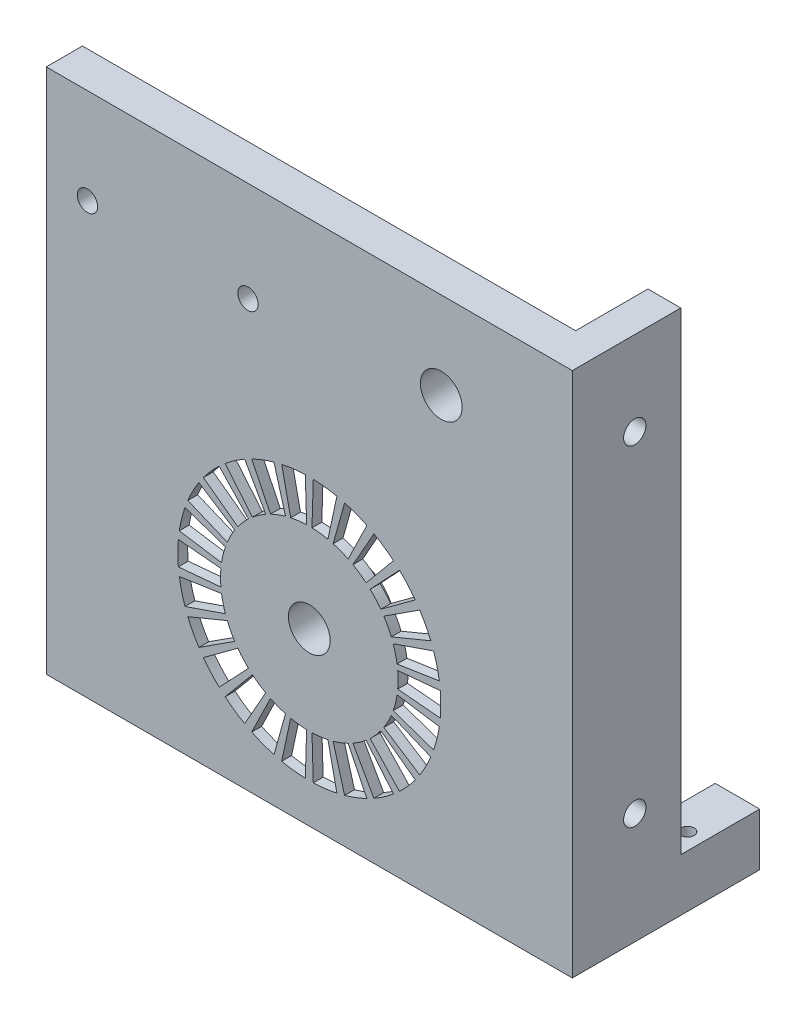
from build123d import *

# Parameters (mm, degrees)
LED_PANEL_W                                     = 80
LED_PANEL_H                                     = 80
EXTRUDE_LED_PANEL_DEPTH                         = 2.5
SKETCH3_R                                       = 5.998748594
SKETCH3_R_2                                     = 6.002880514
BOSS_EXTRUDE2_DEPTH                             = 7
SKETCH1_R                                       = 3.175
CUT_ARROW_INDICATION_HOLES_DEPTH                = 8
SKETCH4_R                                       = 3.175
CUT_HOLE_FOR_SECONDARY_ROD_DEPTH                = 3.5
CUT_HOLE_FOR_SECONDARY_ROD_DEPTH_BACK           = 7
SKETCH2_R                                       = 5.998748594
CUT_SLOT_FOR_PCB_DEPTH                          = 1
BOSS_EXTRUDE3_DEPTH                             = 3
SKETCH9_W                                       = 16.5
SKETCH9_H                                       = 80
BOSS_EXTRUDE4_DEPTH                             = 5
BOSS_EXTRUDE5_DEPTH                             = 12
BOSS_EXTRUDE5_DEPTH_BACK                        = 16.5
SKETCH12_R                                      = 1
CUT_EXTRUDE1_DEPTH                              = 9
SKETCH13_R                                      = 3
BOSS_EXTRUDE6_DEPTH                             = 3
SKETCH14_R                                      = 1.55
CUT_EXTRUDE2_DEPTH                              = 6.5
CSK_FOR_M3_FLAT_HEAD_MACHINE_SCREW1_D           = 3.4
CSK_FOR_M3_FLAT_HEAD_MACHINE_SCREW1_DEPTH       = 5
CSK_FOR_M3_FLAT_HEAD_MACHINE_SCREW1_CSINK_D     = 6.3
CSK_FOR_M3_FLAT_HEAD_MACHINE_SCREW1_CSINK_ANGLE = 90


with BuildPart() as part:
    # LED panel → Extrude LED panel (new body)
    with BuildSketch(Plane.XY):
        Rectangle(LED_PANEL_W, LED_PANEL_H)
    extrude(amount=EXTRUDE_LED_PANEL_DEPTH)

    # Sketch3 → Boss-Extrude2 (add)
    with BuildSketch(Plane.XY.offset(2.5)):
        with Locations((0, -14)):
            Circle(SKETCH3_R)
        with Locations((20.072118416, 26.780555807)):
            Circle(SKETCH3_R_2)
    extrude(amount=-BOSS_EXTRUDE2_DEPTH)

    # Sketch1 → Cut arrow indication holes (cut, through all)
    with BuildSketch(Plane.XY.offset(2.5)):
        with Locations((0, -14)):
            Circle(SKETCH1_R)
        with BuildLine():
            Line((13.444603528, -12.778265176), (19.917931152, -12.190022483))
            ThreePointArc((19.917931152, -12.190022483), (20, -14), (19.917931152, -15.809977517))
            Line((19.917931152, -15.809977517), (13.444603528, -15.221734824))
            ThreePointArc((13.444603528, -15.221734824), (13.5, -14), (13.444603528, -12.778265176))
        make_face()
        with BuildLine():
            Line((13.346308065, -16.031270794), (19.772308244, -17.009290065))
            ThreePointArc((19.772308244, -17.009290065), (19.418836349, -18.786313286), (18.905996301, -20.524055784))
            Line((18.905996301, -20.524055784), (12.761547503, -18.403737654))
            ThreePointArc((12.761547503, -18.403737654), (13.107714535, -17.230761468), (13.346308065, -16.031270794))
        make_face()
        with BuildLine():
            Line((12.472373689, -19.166226337), (18.47759065, -21.653668647))
            ThreePointArc((18.47759065, -21.653668647), (17.709120513, -23.294463441), (16.795313665, -24.858979644))
            Line((16.795313665, -24.858979644), (11.336836724, -21.32981126))
            ThreePointArc((11.336836724, -21.32981126), (11.953656346, -20.273762823), (12.472373689, -19.166226337))
        make_face()
        with BuildLine():
            Line((10.873590289, -22.000939583), (16.109022651, -25.853243827))
            ThreePointArc((16.109022651, -25.853243827), (14.970214963, -27.262453165), (13.708548447, -28.562819078))
            Line((13.708548447, -28.562819078), (9.253270202, -23.829902877))
            ThreePointArc((9.253270202, -23.829902877), (10.1048951, -22.952155886), (10.873590289, -22.000939583))
        make_face()
        with BuildLine():
            Line((8.642873346, -24.370667304), (12.804256809, -29.363951561))
            ThreePointArc((12.804256809, -29.363951561), (11.361294935, -30.459677318), (9.825092222, -31.4203204))
            Line((9.825092222, -31.4203204), (6.63193725, -25.75871627))
            ThreePointArc((6.63193725, -25.75871627), (7.668874081, -25.11028219), (8.642873346, -24.370667304))
        make_face()
        with BuildLine():
            Line((5.90986402, -26.137689536), (8.755354103, -31.981762275))
            ThreePointArc((8.755354103, -31.981762275), (7.092097741, -32.700324854), (5.370637349, -33.265416021))
            Line((5.370637349, -33.265416021), (3.625180211, -27.004155814))
            ThreePointArc((3.625180211, -27.004155814), (4.787165975, -26.622719276), (5.90986402, -26.137689536))
        make_face()
        with BuildLine():
            Line((2.833394878, -27.199313371), (4.197622041, -33.554538327))
            ThreePointArc((4.197622041, -33.554538327), (2.410733605, -33.854177482), (0.604060556, -33.99087569))
            Line((0.604060556, -33.99087569), (0.407740875, -27.493841091))
            ThreePointArc((0.407740875, -27.493841091), (1.627245183, -27.4015698), (2.833394878, -27.199313371))
        make_face()
        with BuildLine():
            Line((-0.407740875, -27.493841091), (-0.604060556, -33.99087569))
            ThreePointArc((-0.604060556, -33.99087569), (-2.410733605, -33.854177482), (-4.197622041, -33.554538327))
            Line((-4.197622041, -33.554538327), (-2.833394878, -27.199313371))
            ThreePointArc((-2.833394878, -27.199313371), (-1.627245183, -27.4015698), (-0.407740875, -27.493841091))
        make_face()
        with BuildLine():
            Line((-3.625180211, -27.004155814), (-5.370637349, -33.265416021))
            ThreePointArc((-5.370637349, -33.265416021), (-7.092097741, -32.700324854), (-8.755354103, -31.981762275))
            Line((-8.755354103, -31.981762275), (-5.90986402, -26.137689536))
            ThreePointArc((-5.90986402, -26.137689536), (-4.787165975, -26.622719276), (-3.625180211, -27.004155814))
        make_face()
        with BuildLine():
            Line((-6.63193725, -25.75871627), (-9.825092222, -31.4203204))
            ThreePointArc((-9.825092222, -31.4203204), (-11.361294935, -30.459677318), (-12.804256809, -29.363951561))
            Line((-12.804256809, -29.363951561), (-8.642873346, -24.370667304))
            ThreePointArc((-8.642873346, -24.370667304), (-7.668874081, -25.11028219), (-6.63193725, -25.75871627))
        make_face()
        with BuildLine():
            Line((-9.253270202, -23.829902877), (-13.708548447, -28.562819078))
            ThreePointArc((-13.708548447, -28.562819078), (-14.970214963, -27.262453165), (-16.109022651, -25.853243827))
            Line((-16.109022651, -25.853243827), (-10.873590289, -22.000939583))
            ThreePointArc((-10.873590289, -22.000939583), (-10.1048951, -22.952155886), (-9.253270202, -23.829902877))
        make_face()
        with BuildLine():
            Line((-11.336836724, -21.32981126), (-16.795313665, -24.858979644))
            ThreePointArc((-16.795313665, -24.858979644), (-17.709120513, -23.294463441), (-18.47759065, -21.653668647))
            Line((-18.47759065, -21.653668647), (-12.472373689, -19.166226337))
            ThreePointArc((-12.472373689, -19.166226337), (-11.953656346, -20.273762823), (-11.336836724, -21.32981126))
        make_face()
        with BuildLine():
            Line((-12.761547503, -18.403737654), (-18.905996301, -20.524055784))
            ThreePointArc((-18.905996301, -20.524055784), (-19.418836349, -18.786313286), (-19.772308244, -17.009290065))
            Line((-19.772308244, -17.009290065), (-13.346308065, -16.031270794))
            ThreePointArc((-13.346308065, -16.031270794), (-13.107714535, -17.230761468), (-12.761547503, -18.403737654))
        make_face()
        with BuildLine():
            Line((-13.444603528, -15.221734824), (-19.917931152, -15.809977517))
            ThreePointArc((-19.917931152, -15.809977517), (-20, -14), (-19.917931152, -12.190022483))
            Line((-19.917931152, -12.190022483), (-13.444603528, -12.778265176))
            ThreePointArc((-13.444603528, -12.778265176), (-13.5, -14), (-13.444603528, -15.221734824))
        make_face()
        with BuildLine():
            Line((-13.346308065, -11.968729206), (-19.772308244, -10.990709935))
            ThreePointArc((-19.772308244, -10.990709935), (-19.418836349, -9.213686714), (-18.905996301, -7.475944216))
            Line((-18.905996301, -7.475944216), (-12.761547503, -9.596262346))
            ThreePointArc((-12.761547503, -9.596262346), (-13.107714535, -10.769238532), (-13.346308065, -11.968729206))
        make_face()
        with BuildLine():
            Line((-12.472373689, -8.833773663), (-18.47759065, -6.346331353))
            ThreePointArc((-18.47759065, -6.346331353), (-17.709120513, -4.705536559), (-16.795313665, -3.141020356))
            Line((-16.795313665, -3.141020356), (-11.336836724, -6.67018874))
            ThreePointArc((-11.336836724, -6.67018874), (-11.953656346, -7.726237177), (-12.472373689, -8.833773663))
        make_face()
        with BuildLine():
            Line((-10.873590289, -5.999060417), (-16.109022651, -2.146756173))
            ThreePointArc((-16.109022651, -2.146756173), (-14.970214963, -0.737546835), (-13.708548447, 0.562819078))
            Line((-13.708548447, 0.562819078), (-9.253270202, -4.170097123))
            ThreePointArc((-9.253270202, -4.170097123), (-10.1048951, -5.047844114), (-10.873590289, -5.999060417))
        make_face()
        with BuildLine():
            Line((-8.642873346, -3.629332696), (-12.804256809, 1.363951561))
            ThreePointArc((-12.804256809, 1.363951561), (-11.361294935, 2.459677318), (-9.825092222, 3.4203204))
            Line((-9.825092222, 3.4203204), (-6.63193725, -2.24128373))
            ThreePointArc((-6.63193725, -2.24128373), (-7.668874081, -2.88971781), (-8.642873346, -3.629332696))
        make_face()
        with BuildLine():
            Line((-5.90986402, -1.862310464), (-8.755354103, 3.981762275))
            ThreePointArc((-8.755354103, 3.981762275), (-7.092097741, 4.700324854), (-5.370637349, 5.265416021))
            Line((-5.370637349, 5.265416021), (-3.625180211, -0.995844186))
            ThreePointArc((-3.625180211, -0.995844186), (-4.787165975, -1.377280724), (-5.90986402, -1.862310464))
        make_face()
        with BuildLine():
            Line((-2.833394878, -0.800686629), (-4.197622041, 5.554538327))
            ThreePointArc((-4.197622041, 5.554538327), (-2.410733605, 5.854177482), (-0.604060556, 5.99087569))
            Line((-0.604060556, 5.99087569), (-0.407740875, -0.506158909))
            ThreePointArc((-0.407740875, -0.506158909), (-1.627245183, -0.5984302), (-2.833394878, -0.800686629))
        make_face()
        with BuildLine():
            Line((0.407740875, -0.506158909), (0.604060556, 5.99087569))
            ThreePointArc((0.604060556, 5.99087569), (2.410733605, 5.854177482), (4.197622041, 5.554538327))
            Line((4.197622041, 5.554538327), (2.833394878, -0.800686629))
            ThreePointArc((2.833394878, -0.800686629), (1.627245183, -0.5984302), (0.407740875, -0.506158909))
        make_face()
        with BuildLine():
            Line((3.625180211, -0.995844186), (5.370637349, 5.265416021))
            ThreePointArc((5.370637349, 5.265416021), (7.092097741, 4.700324854), (8.755354103, 3.981762275))
            Line((8.755354103, 3.981762275), (5.90986402, -1.862310464))
            ThreePointArc((5.90986402, -1.862310464), (4.787165975, -1.377280724), (3.625180211, -0.995844186))
        make_face()
        with BuildLine():
            Line((6.63193725, -2.24128373), (9.825092222, 3.4203204))
            ThreePointArc((9.825092222, 3.4203204), (11.361294935, 2.459677318), (12.804256809, 1.363951561))
            Line((12.804256809, 1.363951561), (8.642873346, -3.629332696))
            ThreePointArc((8.642873346, -3.629332696), (7.668874081, -2.88971781), (6.63193725, -2.24128373))
        make_face()
        with BuildLine():
            Line((9.253270202, -4.170097123), (13.708548447, 0.562819078))
            ThreePointArc((13.708548447, 0.562819078), (14.970214963, -0.737546835), (16.109022651, -2.146756173))
            Line((16.109022651, -2.146756173), (10.873590289, -5.999060417))
            ThreePointArc((10.873590289, -5.999060417), (10.1048951, -5.047844114), (9.253270202, -4.170097123))
        make_face()
        with BuildLine():
            Line((11.336836724, -6.67018874), (16.795313665, -3.141020356))
            ThreePointArc((16.795313665, -3.141020356), (17.709120513, -4.705536559), (18.47759065, -6.346331353))
            Line((18.47759065, -6.346331353), (12.472373689, -8.833773663))
            ThreePointArc((12.472373689, -8.833773663), (11.953656346, -7.726237177), (11.336836724, -6.67018874))
        make_face()
        with BuildLine():
            Line((12.761547503, -9.596262346), (18.905996301, -7.475944216))
            ThreePointArc((18.905996301, -7.475944216), (19.418836349, -9.213686714), (19.772308244, -10.990709935))
            Line((19.772308244, -10.990709935), (13.346308065, -11.968729206))
            ThreePointArc((13.346308065, -11.968729206), (13.107714535, -10.769238532), (12.761547503, -9.596262346))
        make_face()
    extrude(amount=-CUT_ARROW_INDICATION_HOLES_DEPTH, mode=Mode.SUBTRACT)

    # Sketch4 → Cut hole for secondary rod (cut, two sides)
    with BuildSketch(Plane.XY) as cut_hole_for_secondary_rod_sk:
        with Locations((20.072118416, 26.780555807)):
            Circle(SKETCH4_R)
    extrude(amount=CUT_HOLE_FOR_SECONDARY_ROD_DEPTH, mode=Mode.SUBTRACT)
    extrude(cut_hole_for_secondary_rod_sk.sketch, amount=-CUT_HOLE_FOR_SECONDARY_ROD_DEPTH_BACK, mode=Mode.SUBTRACT)

    # Sketch2 → Cut slot for PCB (cut)
    with BuildSketch(Plane(origin=(0, 0, 0), x_dir=(-1, 0, 0), z_dir=(0, 0, -1))):
        with BuildLine():
            Line((-1, 13.481812167), (-1, 14.981812167))
            Line((-1, 14.981812167), (1, 14.981812167))
            Line((1, 14.981812167), (1, 13.481812167))
            ThreePointArc((1, 13.481812167), (27.200508752, -9.952491679), (8.958236434, -40))
            Line((8.958236434, -40), (-8.958236434, -40))
            ThreePointArc((-8.958236434, -40), (-27.200508752, -9.952491679), (-1, 13.481812167))
        make_face()
        with Locations((0, -14)):
            Circle(SKETCH2_R, mode=Mode.SUBTRACT)
    extrude(amount=-CUT_SLOT_FOR_PCB_DEPTH, mode=Mode.SUBTRACT)

    # Sketch6 → Boss-Extrude3 (add)
    with BuildSketch(Plane(origin=(0, 0, 0), x_dir=(-1, 0, 0), z_dir=(0, 0, -1))):
        Polygon((-40, 40), (40, 40), (40, -40), (37, -40), (37, 37), (14.471436817, 37), (-40, 1.998731966), (-40, 5.56467809), (8.921860477, 37), (-40, 37), align=None)
    extrude(amount=BOSS_EXTRUDE3_DEPTH)

    # Sketch9 → Boss-Extrude4 (add)
    with BuildSketch(Plane(origin=(40, 0, 0), x_dir=(0, 0, -1), z_dir=(1, 0, 0))):
        with Locations((5.75, 0)):
            Rectangle(SKETCH9_W, SKETCH9_H)
    extrude(amount=-BOSS_EXTRUDE4_DEPTH)

    # Sketch11 → Boss-Extrude5 (add, two sides)
    with BuildSketch(Plane(origin=(0, 0, -14), x_dir=(-1, 0, 0), z_dir=(0, 0, -1))) as boss_extrude5_sk:
        Polygon((-40, -40), (-35, -40), (-33.230871041, -32), (-40, -32), align=None)
    extrude(amount=BOSS_EXTRUDE5_DEPTH)
    extrude(boss_extrude5_sk.sketch, amount=-BOSS_EXTRUDE5_DEPTH_BACK)

    # Sketch12 → Cut-Extrude1 (cut, through all)
    with BuildSketch(Plane(origin=(0, -32, 0), x_dir=(1, 0, 0), z_dir=(0, 1, 0))):
        with Locations((37.5, 17.53)):
            Circle(SKETCH12_R)
    extrude(amount=-CUT_EXTRUDE1_DEPTH, mode=Mode.SUBTRACT)

    # Sketch13 → Boss-Extrude6 (add)
    with BuildSketch(Plane(origin=(0, 0, 0), x_dir=(-1, 0, 0), z_dir=(0, 0, -1))):
        with Locations((33.74, 25.5)):
            Circle(SKETCH13_R)
        with Locations((9.33, 24.81)):
            Circle(SKETCH13_R)
    extrude(amount=BOSS_EXTRUDE6_DEPTH)

    # Sketch14 → Cut-Extrude2 (cut, through all)
    with BuildSketch(Plane(origin=(0, 0, -3), x_dir=(-1, 0, 0), z_dir=(0, 0, -1))):
        with Locations((33.74, 25.5)):
            Circle(SKETCH14_R)
        with Locations((9.33, 24.81)):
            Circle(SKETCH14_R)
    extrude(amount=-CUT_EXTRUDE2_DEPTH, mode=Mode.SUBTRACT)

    # CSK for M3 Flat Head Machine Screw1
    with Locations(Plane.ZY.offset(-35)):
        with Locations((-7, 27.197122382), (-7, -23.077936446)):
            CounterSinkHole(CSK_FOR_M3_FLAT_HEAD_MACHINE_SCREW1_D / 2, CSK_FOR_M3_FLAT_HEAD_MACHINE_SCREW1_CSINK_D / 2, depth=CSK_FOR_M3_FLAT_HEAD_MACHINE_SCREW1_DEPTH, counter_sink_angle=CSK_FOR_M3_FLAT_HEAD_MACHINE_SCREW1_CSINK_ANGLE)


solid = part.part
